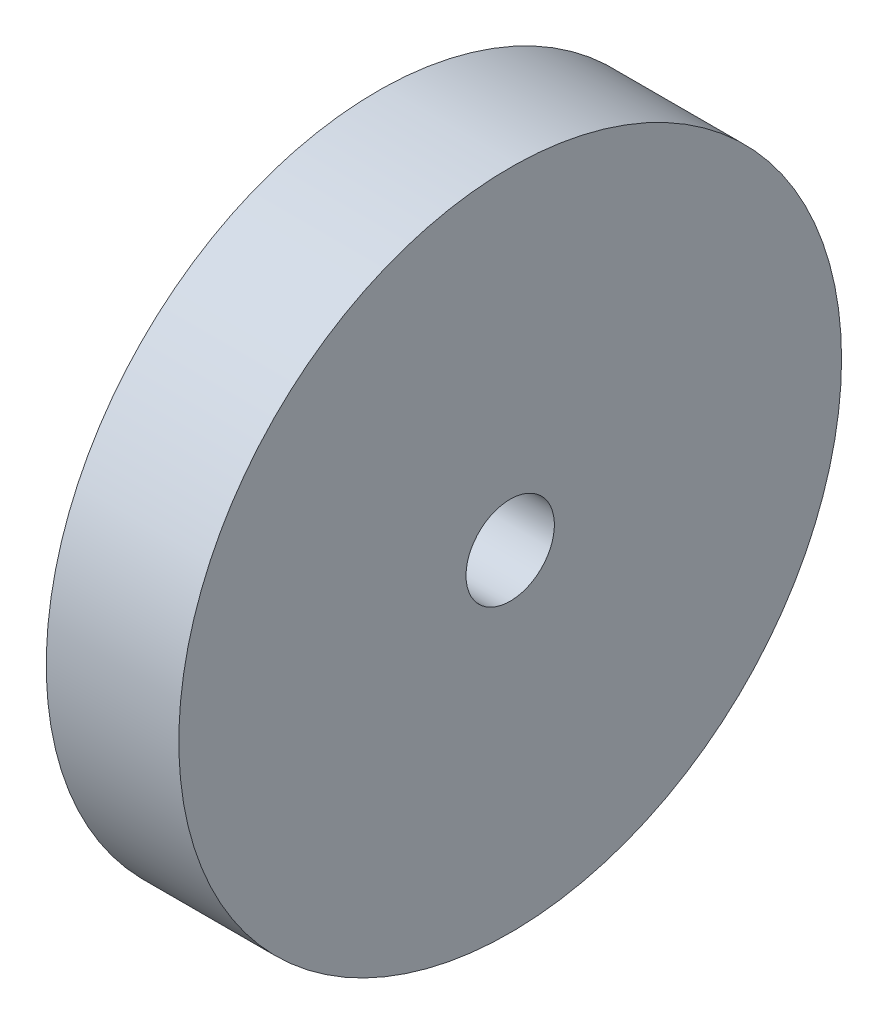
from build123d import *

# Parameters (mm, degrees)
SKETCH2_R           = 37.5
BOSS_EXTRUDE1_DEPTH = 15
SKETCH4_R           = 5
CUT_EXTRUDE1_DEPTH  = 16


with BuildPart() as part:
    # Sketch2 → Boss-Extrude1 (new body)
    with BuildSketch(Plane(origin=(0, 0, 0), x_dir=(0, 0, -1), z_dir=(1, 0, 0))):
        Circle(SKETCH2_R)
    extrude(amount=BOSS_EXTRUDE1_DEPTH)

    # Sketch4 → Cut-Extrude1 (cut, through all)
    with BuildSketch(Plane.ZY):
        Circle(SKETCH4_R)
    extrude(amount=-CUT_EXTRUDE1_DEPTH, mode=Mode.SUBTRACT)


solid = part.part
